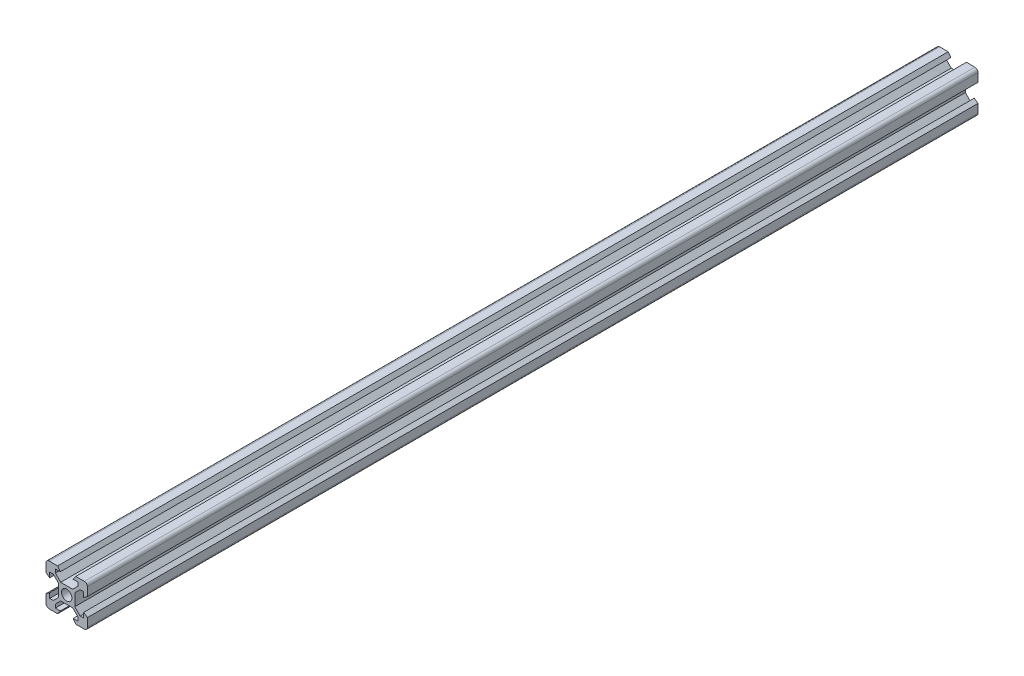
from build123d import *

# Parameters (mm, degrees)
SKETCH_1_R      = 2.5
EXTRUDE_1_DEPTH = 430


with BuildPart() as part:
    # 草图1 → 凸台-拉伸1 (new body)
    with BuildSketch(Plane.XY):
        with BuildLine():
            Line((14.8, 34.821428571), (18.9, 34.821428571))
            Line((18.9, 34.821428571), (20.2, 33.021428571))
            Line((20.2, 33.021428571), (17.8, 33.021428571))
            Line((17.8, 33.021428571), (17.8, 31.311378065))
            Line((17.8, 31.311378065), (20.389949494, 28.721428571))
            Line((20.389949494, 28.721428571), (26.210050506, 28.721428571))
            Line((26.210050506, 28.721428571), (28.8, 31.311378065))
            Line((28.8, 31.311378065), (28.8, 33.021428571))
            Line((28.8, 33.021428571), (26.4, 33.021428571))
            Line((26.4, 33.021428571), (27.7, 34.821428571))
            Line((27.7, 34.821428571), (31.8, 34.821428571))
            ThreePointArc((31.8, 34.821428571), (32.860660172, 34.382088743), (33.3, 33.321428571))
            Line((33.3, 33.321428571), (33.3, 29.221428571))
            Line((33.3, 29.221428571), (31.5, 27.921428571))
            Line((31.5, 27.921428571), (31.5, 30.321428571))
            Line((31.5, 30.321428571), (29.789949494, 30.321428571))
            Line((29.789949494, 30.321428571), (27.2, 27.731479078))
            Line((27.2, 27.731479078), (27.2, 21.911378065))
            Line((27.2, 21.911378065), (29.789949494, 19.321428571))
            Line((29.789949494, 19.321428571), (31.5, 19.321428571))
            Line((31.5, 19.321428571), (31.5, 21.721428571))
            Line((31.5, 21.721428571), (33.3, 20.421428571))
            Line((33.3, 20.421428571), (33.3, 16.321428571))
            ThreePointArc((33.3, 16.321428571), (32.860660172, 15.2607684), (31.8, 14.821428571))
            Line((31.8, 14.821428571), (27.7, 14.821428571))
            Line((27.7, 14.821428571), (26.4, 16.621428571))
            Line((26.4, 16.621428571), (28.8, 16.621428571))
            Line((28.8, 16.621428571), (28.8, 18.331479078))
            Line((28.8, 18.331479078), (26.210050506, 20.921428571))
            Line((26.210050506, 20.921428571), (20.389949494, 20.921428571))
            Line((20.389949494, 20.921428571), (17.8, 18.331479078))
            Line((17.8, 18.331479078), (17.8, 16.621428571))
            Line((17.8, 16.621428571), (20.2, 16.621428571))
            Line((20.2, 16.621428571), (18.9, 14.821428571))
            Line((18.9, 14.821428571), (14.8, 14.821428571))
            ThreePointArc((14.8, 14.821428571), (13.739339828, 15.2607684), (13.3, 16.321428571))
            Line((13.3, 16.321428571), (13.3, 20.421428571))
            Line((13.3, 20.421428571), (15.1, 21.721428571))
            Line((15.1, 21.721428571), (15.1, 19.321428571))
            Line((15.1, 19.321428571), (16.810050506, 19.321428571))
            Line((16.810050506, 19.321428571), (19.4, 21.911378065))
            Line((19.4, 21.911378065), (19.4, 27.731479078))
            Line((19.4, 27.731479078), (16.810050506, 30.321428571))
            Line((16.810050506, 30.321428571), (15.1, 30.321428571))
            Line((15.1, 30.321428571), (15.1, 27.921428571))
            Line((15.1, 27.921428571), (13.3, 29.221428571))
            Line((13.3, 29.221428571), (13.3, 33.321428571))
            ThreePointArc((13.3, 33.321428571), (13.739339828, 34.382088743), (14.8, 34.821428571))
        make_face()
        with Locations((23.3, 24.821428571)):
            Circle(SKETCH_1_R, mode=Mode.SUBTRACT)
    extrude(amount=EXTRUDE_1_DEPTH)


solid = part.part
